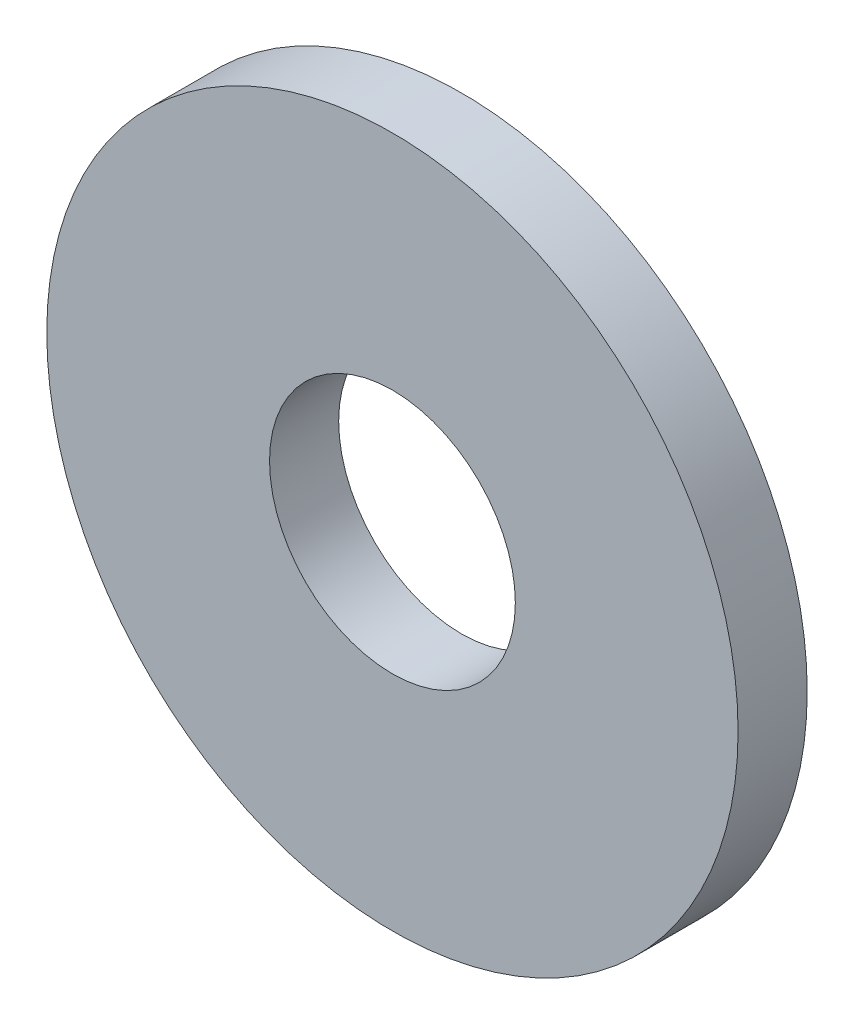
from build123d import *

# Parameters (mm, degrees)
SKETCH1_R           = 4.5
SKETCH1_R_2         = 1.6
BOSS_EXTRUDE1_DEPTH = 0.9


with BuildPart() as part:
    # Sketch1 → Boss-Extrude1 (new body)
    with BuildSketch(Plane.XY):
        Circle(SKETCH1_R)
        Circle(SKETCH1_R_2, mode=Mode.SUBTRACT)
    extrude(amount=BOSS_EXTRUDE1_DEPTH)


solid = part.part
